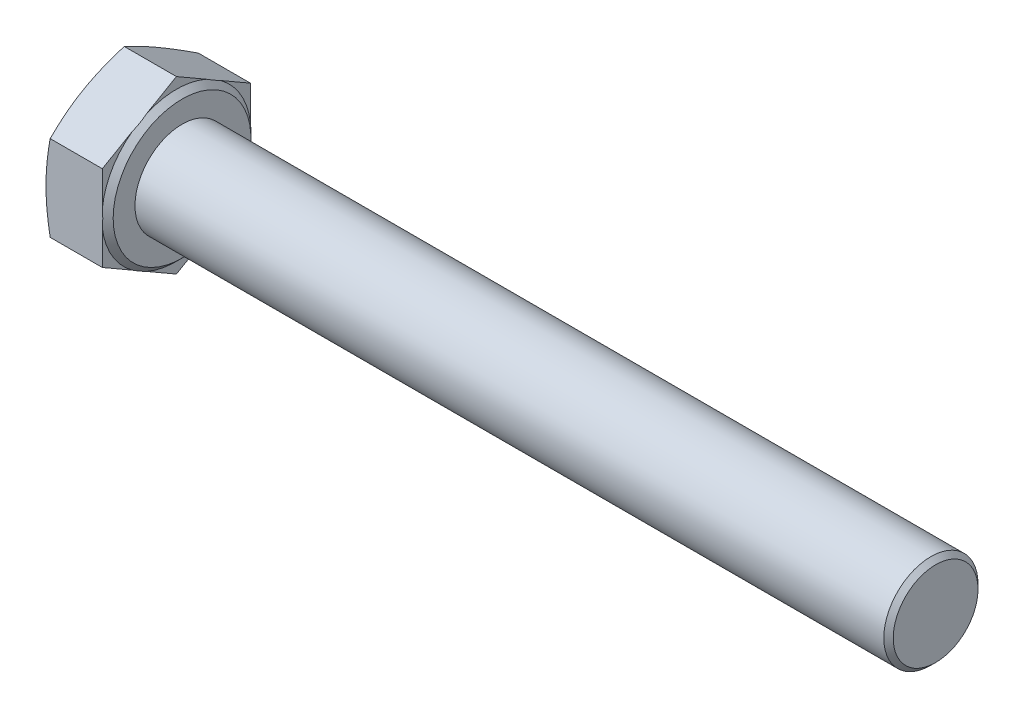
from build123d import *

# Parameters (mm, degrees)
BASEHEAD_DEPTH = 6.58
SKETCH5_R      = 5
BASEBODY_DEPTH = 80
CHAMFER1_SIZE  = 0.5


with BuildPart() as part:
    # Sketch2 → BaseHead (new body)
    with BuildSketch(Plane(origin=(0, 0, 0), x_dir=(0, 0, -1), z_dir=(1, 0, 0))):
        Polygon((7.865, -4.540859867), (7.865, 4.540859867), (0, 9.081719734), (-7.865, 4.540859867), (-7.865, -4.540859867), (0, -9.081719734), align=None)
    extrude(amount=BASEHEAD_DEPTH)

    # Sketch3 → BearingFace (revolve, cut)
    with BuildSketch(Plane.XY):
        Polygon((6.58, 9.081719734), (6.58, 7.315), (5.98, 7.915), (5.98, 9.081719734), align=None)
    revolve(axis=Axis((-0.957090588, 0, 0), (1, 0, 0)), mode=Mode.SUBTRACT)

    # Sketch4 → HeadChamfer (revolve, cut)
    with BuildSketch(Plane.XY):
        Polygon((0, 9.081719734), (0.442849767, 9.081719734), (0, 7.865), align=None)
    revolve(axis=Axis((-0.493528746, 0, 0), (1, 0, 0)), mode=Mode.SUBTRACT)

    # Sketch5 → BaseBody (add)
    with BuildSketch(Plane(origin=(6.58, 0, 0), x_dir=(0, 0, -1), z_dir=(1, 0, 0))):
        Circle(SKETCH5_R)
    extrude(amount=BASEBODY_DEPTH)

    # Chamfer1
    chamfer1_edges = [part.edges().sort_by_distance(p)[0] for p in [
        (86.58, 0, 5),
    ]]
    chamfer(chamfer1_edges, length=CHAMFER1_SIZE)


solid = part.part
